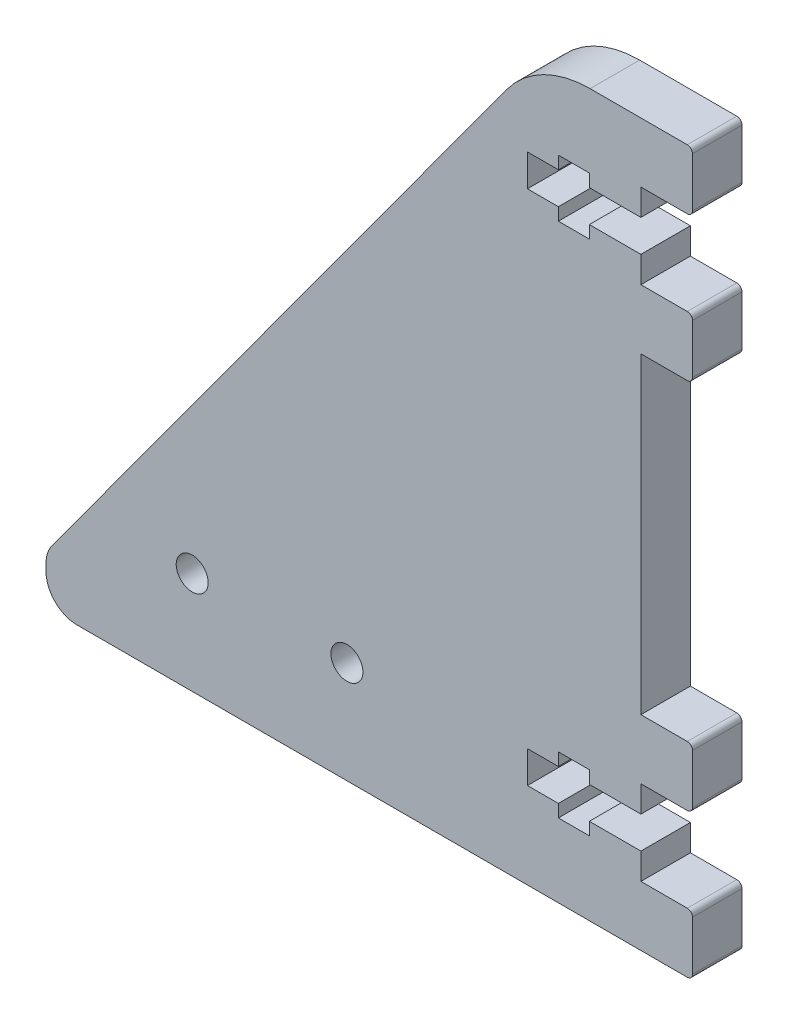
from build123d import *

# Parameters (mm, degrees)
BOSS_EXTRU_1_DEPTH                  = 4.8
ENL_V_MAT_EXTRU_1_DEPTH             = 2.3
D_POUILLE1_ANGLE                    = -36.151625355
DIAM_TRE_DU_PER_AGE_3_1_3_1_1_D     = 3.1
DIAM_TRE_DU_PER_AGE_3_1_3_1_1_DEPTH = 4.8
CONG_1_R                            = 10
ESQUISSE5_R                         = 1.55
BOSS_EXTRU_2_DEPTH                  = 4.8
ENL_V_MAT_EXTRU_2_DEPTH             = 78.657948853
ESQUISSE6_W                         = 3
ESQUISSE6_H                         = 3.1
ESQUISSE6_H_2                       = 1.22
ESQUISSE6_W_2                       = 5
ESQUISSE6_H_3                       = 1.23
ENL_V_MAT_EXTRU_3_DEPTH             = 76.557273061
ESQUISSE7_W                         = 5
ESQUISSE7_H                         = 5.8
BOSS_EXTRU_3_DEPTH                  = 4.8
CONG_2_R                            = 3
CONG_3_R                            = 0.5
CHANFREIN1_SIZE                     = 2


with BuildPart() as part:
    # Esquisse1 → Boss.-Extru.1 (new body)
    with BuildSketch(Plane(origin=(0, 0, 0), x_dir=(-1, 0, 0), z_dir=(0, 0, -1))):
        with BuildLine():
            Line((38, -9.9), (38, 60))
            Line((38, 60), (-12, 60))
            Line((-12, 60), (-12, 11.9))
            ThreePointArc((-12, 11.9), (-11, 10.9), (-12, 9.9))
            Line((-12, 9.9), (-17, 9.9))
            Line((-17, 9.9), (-17, 4.1))
            Line((-17, 4.1), (-12, 4.1))
            ThreePointArc((-12, 4.1), (-11, 3.1), (-12, 2.1))
            Line((-12, 2.1), (-12, -2.1))
            ThreePointArc((-12, -2.1), (-11, -3.1), (-12, -4.1))
            Line((-12, -4.1), (-17, -4.1))
            Line((-17, -4.1), (-17, -9.9))
            Line((-17, -9.9), (38, -9.9))
        make_face()
    extrude(amount=-BOSS_EXTRU_1_DEPTH)

    # Esquisse2 → Enl_v. mat.-Extru.1 (cut)
    with BuildSketch(Plane.XY.offset(4.8)):
        with BuildLine():
            Line((-38, -5.25), (7, -5.25))
            ThreePointArc((7, -5.25), (8, -4.25), (7, -3.25))
            Line((7, -3.25), (7, 3.25))
            ThreePointArc((7, 3.25), (8, 4.25), (7, 5.25))
            Line((7, 5.25), (-38, 5.25))
            Line((-38, 5.25), (-38, -5.25))
        make_face()
    extrude(amount=-ENL_V_MAT_EXTRU_1_DEPTH, mode=Mode.SUBTRACT)

    # D_pouille1
    d_pouille1_faces = [part.faces().sort_by_distance(p)[0] for p in [
        (-38, 26.992889488, 2.303049427),
    ]]
    draft(d_pouille1_faces, Plane(origin=(7, 5.25, 2.5), x_dir=(-1, 0, 0), z_dir=(0, -1, 0)), D_POUILLE1_ANGLE)

    # Diam_tre du per_age _3.1 _3.1_1
    with Locations(Plane(origin=(0, 0, 0), x_dir=(-1, 0, 0), z_dir=(0, 0, -1))):
        with Locations((16.5, 0), (31.5, 0)):
            Hole(DIAM_TRE_DU_PER_AGE_3_1_3_1_1_D / 2, depth=DIAM_TRE_DU_PER_AGE_3_1_3_1_1_DEPTH)

    # Cong_1
    cong_1_edges = [part.edges().sort_by_distance(p)[0] for p in [
        (2, 60, 2.4),
    ]]
    fillet(cong_1_edges, radius=CONG_1_R)

    # Esquisse5 → Boss.-Extru.2 (add)
    with BuildSketch(Plane.XY.offset(4.8)):
        with BuildLine():
            Line((-38, 5.25), (-45.671232877, -5.25))
            Line((-45.671232877, -5.25), (7, -5.25))
            ThreePointArc((7, -5.25), (8, -4.25), (7, -3.25))
            Line((7, -3.25), (7, 3.25))
            ThreePointArc((7, 3.25), (8, 4.25), (7, 5.25))
            Line((7, 5.25), (-38, 5.25))
        make_face()
        with Locations(Location((-31.5, 0, 0), (0, 0, 180))):
            Circle(ESQUISSE5_R, mode=Mode.SUBTRACT)
        with Locations(Location((-16.5, 0, 0), (0, 0, 180))):
            Circle(ESQUISSE5_R, mode=Mode.SUBTRACT)
        with BuildLine():
            ThreePointArc((12, -2.1), (11, -3.1), (12, -4.1))
            Line((12, -4.1), (12, -2.1))
        make_face()
        with BuildLine():
            ThreePointArc((12, 4.1), (11, 3.1), (12, 2.1))
            Line((12, 2.1), (12, 4.1))
        make_face()
        with BuildLine():
            Line((12, 9.9), (12, 11.9))
            ThreePointArc((12, 11.9), (11, 10.9), (12, 9.9))
        make_face()
    extrude(amount=-BOSS_EXTRU_2_DEPTH)

    # Esquisse5_4 → Enl_v. mat.-Extru.2 (cut, through all)
    with BuildSketch(Plane.XY.offset(4.8)):
        Polygon((-45.671232877, -9.9), (-45.671232877, -5.25), (-49.068493151, -9.9), align=None)
    extrude(amount=-ENL_V_MAT_EXTRU_2_DEPTH, mode=Mode.SUBTRACT)

    # Esquisse6 → Enl_v. mat.-Extru.3 (cut, through all)
    with BuildSketch(Plane.XY.offset(4.8)):
        with Locations((2.5, 0)):
            Rectangle(ESQUISSE6_W, ESQUISSE6_H)
        with Locations((5.5, 0)):
            Rectangle(ESQUISSE6_W, ESQUISSE6_H)
        with Locations((5.5, -2.16)):
            Rectangle(ESQUISSE6_W, ESQUISSE6_H_2)
        with Locations((9.5, 0)):
            Rectangle(ESQUISSE6_W_2, ESQUISSE6_H)
        with Locations((5.5, 2.165)):
            Rectangle(ESQUISSE6_W, ESQUISSE6_H_3)
        with Locations((5.5, 47.94)):
            Rectangle(ESQUISSE6_W, ESQUISSE6_H_2)
        with Locations((5.5, 50.1)):
            Rectangle(ESQUISSE6_W, ESQUISSE6_H)
        with Locations((2.5, 50.1)):
            Rectangle(ESQUISSE6_W, ESQUISSE6_H)
        with Locations((5.5, 52.265)):
            Rectangle(ESQUISSE6_W, ESQUISSE6_H_3)
        with Locations((9.5, 50.1)):
            Rectangle(ESQUISSE6_W_2, ESQUISSE6_H)
    extrude(amount=-ENL_V_MAT_EXTRU_3_DEPTH, mode=Mode.SUBTRACT)

    # Esquisse7 → Boss.-Extru.3 (add)
    with BuildSketch(Plane.XY.offset(4.8)):
        with Locations((14.5, 57.1)):
            Rectangle(ESQUISSE7_W, ESQUISSE7_H)
        with Locations((14.5, 43.1)):
            Rectangle(ESQUISSE7_W, ESQUISSE7_H)
    extrude(amount=-BOSS_EXTRU_3_DEPTH)

    # Cong_2
    cong_2_edges = [part.edges().sort_by_distance(p)[0] for p in [
        (-45.671232877, -5.25, 2.4),
        (-45.671232877, -9.9, 2.4),
    ]]
    fillet(cong_2_edges, radius=CONG_2_R)

    # Cong_3
    cong_3_edges = [part.edges().sort_by_distance(p)[0] for p in [
        (17, -9.9, 2.4),
        (17, -4.1, 2.4),
        (17, 4.1, 2.4),
        (17, 9.9, 2.4),
        (17, 46, 2.4),
        (17, 40.2, 2.4),
        (17, 60, 2.4),
        (17, 54.2, 2.4),
    ]]
    fillet(cong_3_edges, radius=CONG_3_R)

    # Chanfrein1
    chanfrein1_edges = [part.edges().sort_by_distance(p)[0] for p in [
        (-31.5, 1.55, 0),
        (-16.5, 1.55, 0),
    ]]
    chamfer(chanfrein1_edges, length=CHANFREIN1_SIZE)


solid = part.part
